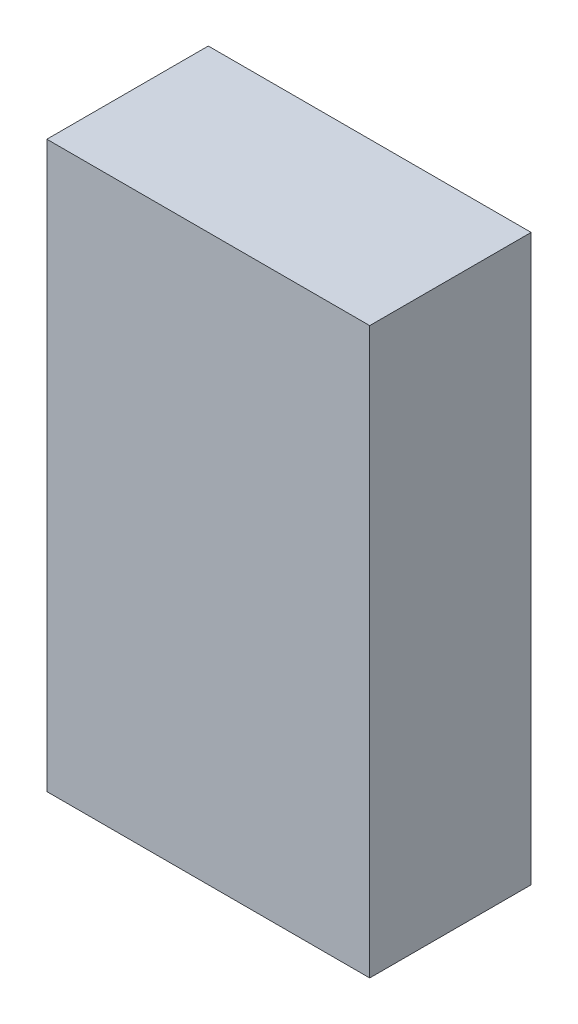
from build123d import *

# Parameters (mm, degrees)
SKETCH1_W           = 50.8
SKETCH1_H           = 88.9
BOSS_EXTRUDE1_DEPTH = 25.4


with BuildPart() as part:
    # Sketch1 → Boss-Extrude1 (new body)
    with BuildSketch(Plane.XY):
        Rectangle(SKETCH1_W, SKETCH1_H)
    extrude(amount=BOSS_EXTRUDE1_DEPTH)


solid = part.part
